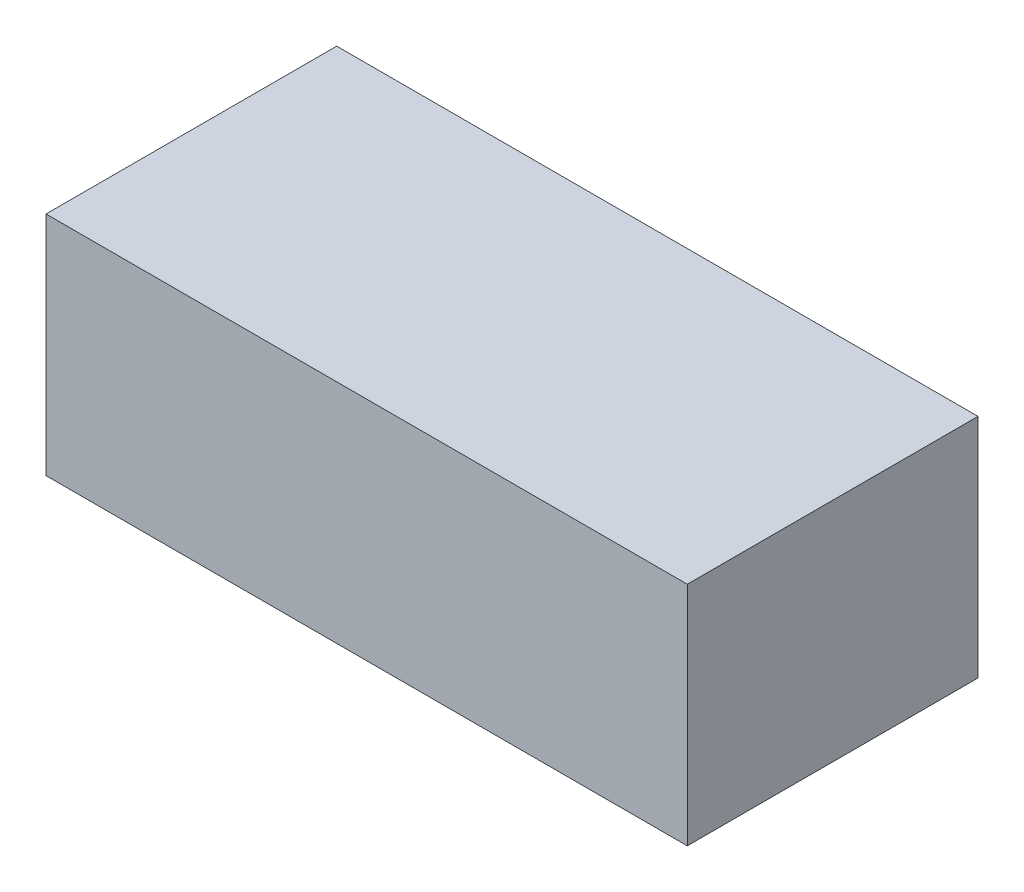
from build123d import *

# Parameters (mm, degrees)
SKETCH2_W           = 75
SKETCH2_H           = 34
BOSS_EXTRUDE1_DEPTH = 26.5


with BuildPart() as part:
    # Sketch2 → Boss-Extrude1 (new body)
    with BuildSketch(Plane(origin=(0, 0, 0), x_dir=(1, 0, 0), z_dir=(0, 1, 0))):
        Rectangle(SKETCH2_W, SKETCH2_H)
    extrude(amount=BOSS_EXTRUDE1_DEPTH)


solid = part.part
